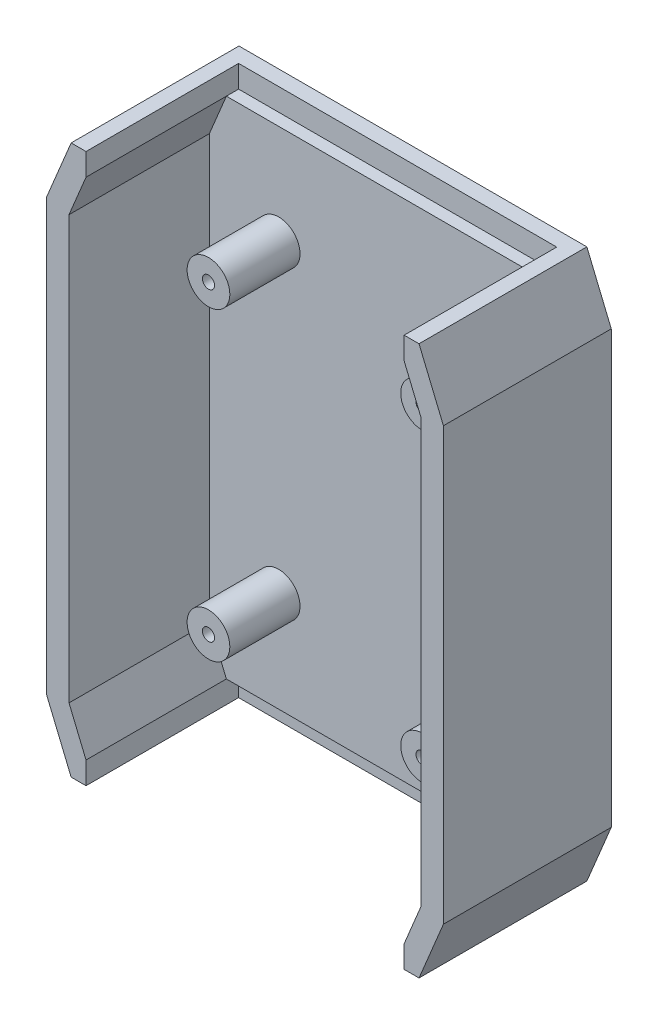
from build123d import *

# Parameters (mm, degrees)
BOSS_EXTRUDE1_DEPTH = 5.715
BOSS_EXTRUDE2_DEPTH = 29.21
SKETCH3_W           = 66.200858932
SKETCH3_H           = 4.6355
CUT_EXTRUDE1_DEPTH  = 31.75
SKETCH4_R           = 4.445
BOSS_EXTRUDE3_DEPTH = 14.605
SKETCH5_R           = 1.27
CUT_EXTRUDE2_DEPTH  = 7.62


with BuildPart() as part:
    # Sketch1 → Boss-Extrude1 (new body)
    with BuildSketch(Plane.XY):
        Polygon((41.275, 44.914422768), (36.195, 57.15), (-36.195, 57.15), (-41.275, 44.914422768), (-41.275, -44.914422768), (-36.195, -57.15), (36.195, -57.15), (41.275, -44.914422768), align=None)
    extrude(amount=BOSS_EXTRUDE1_DEPTH)

    # Sketch2 → Boss-Extrude2 (add)
    with BuildSketch(Plane.XY.offset(5.715)):
        Polygon((-41.275, 44.914422768), (-41.275, -44.914422768), (-36.195, -57.15), (36.195, -57.15), (41.275, -44.914422768), (41.275, 44.914422768), (36.195, 57.15), (-36.195, 57.15), align=None)
        Polygon((-33.100429466, 52.5145), (-36.6395, 43.99037188), (-36.6395, -43.99037188), (-33.100429466, -52.5145), (33.100429466, -52.5145), (36.6395, -43.99037188), (36.6395, 43.99037188), (33.100429466, 52.5145), align=None, mode=Mode.SUBTRACT)
    extrude(amount=BOSS_EXTRUDE2_DEPTH)

    # Sketch3 → Cut-Extrude1 (cut)
    with BuildSketch(Plane.XY.offset(34.925)):
        with Locations((0, 54.83225)):
            Rectangle(SKETCH3_W, SKETCH3_H)
    cut_extrude1 = extrude(amount=-CUT_EXTRUDE1_DEPTH, mode=Mode.SUBTRACT)

    # Mirror1: Cut-Extrude1 across plane
    add(cut_extrude1.mirror(Plane.ZX), mode=Mode.SUBTRACT)

    # Sketch4 → Boss-Extrude3 (add)
    with BuildSketch(Plane.XY.offset(5.715)):
        with Locations((22.225, -31.75)):
            Circle(SKETCH4_R)
        with Locations((-22.225, -31.75)):
            Circle(SKETCH4_R)
        with Locations((22.225, 31.75)):
            Circle(SKETCH4_R)
        with Locations((-22.225, 31.75)):
            Circle(SKETCH4_R)
    extrude(amount=BOSS_EXTRUDE3_DEPTH)

    # Sketch5 → Cut-Extrude2 (cut)
    with BuildSketch(Plane.XY.offset(20.32)):
        with Locations((-22.225, 31.75)):
            Circle(SKETCH5_R)
        with Locations((22.225, 31.75)):
            Circle(SKETCH5_R)
        with Locations((22.225, -31.75)):
            Circle(SKETCH5_R)
        with Locations((-22.225, -31.75)):
            Circle(SKETCH5_R)
    extrude(amount=-CUT_EXTRUDE2_DEPTH, mode=Mode.SUBTRACT)


solid = part.part
